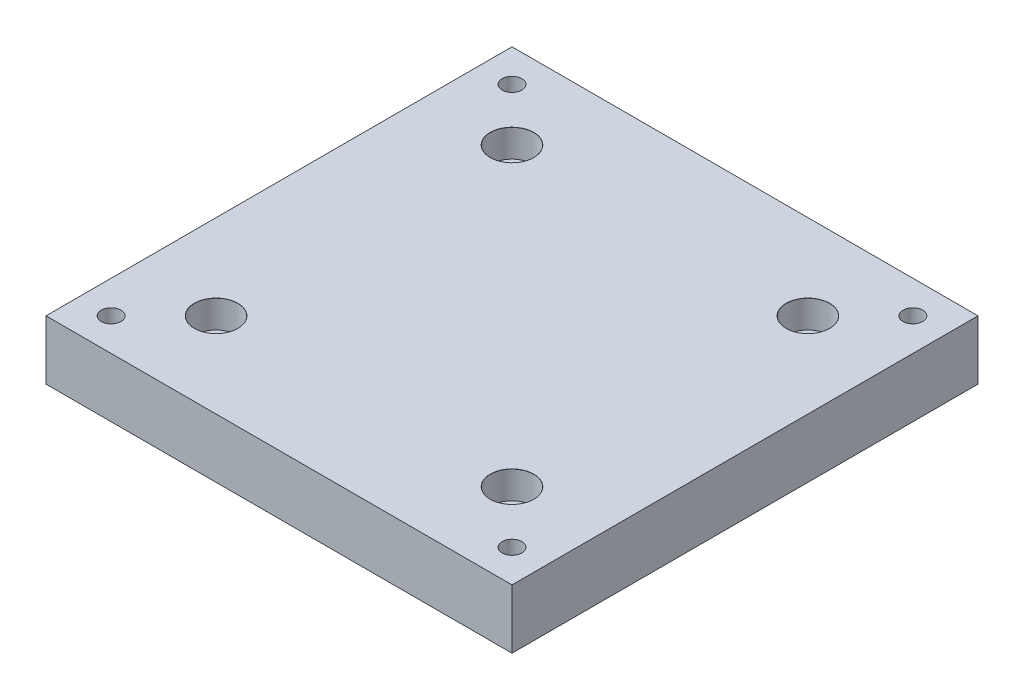
from build123d import *

# Parameters (mm, degrees)
SKETCH1_W                     = 118.11
SKETCH1_H                     = 118.11
BOSS_EXTRUDE1_DEPTH           = 15
CBORE_FOR_M6_SHCS1_AT_2_COUNT = 2
CBORE_FOR_M6_SHCS1_AT_2_PITCH = 75
CBORE_FOR_M6_SHCS1_AT_3_COUNT = 2
CBORE_FOR_M6_SHCS1_AT_3_PITCH = 106.066017178
CBORE_FOR_M6_SHCS1_AT_4_COUNT = 2
CBORE_FOR_M6_SHCS1_AT_4_PITCH = 75
M6X1_0_TAPPED_HOLE1_D         = 5
M6X1_0_TAPPED_HOLE1_DEPTH     = 10
M6X1_0_TAPPED_HOLE1_TIP       = 1.502151548


with BuildPart() as part:
    # Sketch1 → Boss-Extrude1 (new body)
    with BuildSketch(Plane(origin=(0, 0, 0), x_dir=(1, 0, 0), z_dir=(0, 1, 0))):
        Rectangle(SKETCH1_W, SKETCH1_H)
    extrude(amount=-BOSS_EXTRUDE1_DEPTH)

    # Sketch5 → CBORE for M6 SHCS1 (revolve, cut)
    with BuildSketch(Plane(origin=(-37.5, 0, 37.5), x_dir=(0, 0, 1), z_dir=(1, 0, 0))):
        Polygon((0, 0), (0, 16.982840043), (3.3, 15), (3.3, 7), (5.5, 7), (5.5, 0.025), (5.525, 0), align=None)
    cbore_for_m6_shcs1 = revolve(axis=Axis((-37.5, 6.35, 37.5), (0, -1, 0)), mode=Mode.SUBTRACT)

    # CBORE for M6 SHCS1 at 2: CBORE for M6 SHCS1 ×2
    with Locations(*[(i * CBORE_FOR_M6_SHCS1_AT_2_PITCH, 0, 0) for i in range(1, CBORE_FOR_M6_SHCS1_AT_2_COUNT)]):
        add(cbore_for_m6_shcs1, mode=Mode.SUBTRACT)

    # CBORE for M6 SHCS1 at 3: CBORE for M6 SHCS1 ×2
    with Locations(*[Vector(0.707106781, 0, -0.707106781) * (i * CBORE_FOR_M6_SHCS1_AT_3_PITCH) for i in range(1, CBORE_FOR_M6_SHCS1_AT_3_COUNT)]):
        add(cbore_for_m6_shcs1, mode=Mode.SUBTRACT)

    # CBORE for M6 SHCS1 at 4: CBORE for M6 SHCS1 ×2
    with Locations(*[(0, 0, -i * CBORE_FOR_M6_SHCS1_AT_4_PITCH) for i in range(1, CBORE_FOR_M6_SHCS1_AT_4_COUNT)]):
        add(cbore_for_m6_shcs1, mode=Mode.SUBTRACT)

    # M6x1.0 Tapped Hole1
    with Locations(Plane(origin=(0, 0, 0), x_dir=(1, 0, 0), z_dir=(0, 1, 0))):
        with Locations((-50.8, -50.8), (-50.8, 50.8), (50.8, 50.8), (50.8, -50.8)):
            Hole(M6X1_0_TAPPED_HOLE1_D / 2, depth=M6X1_0_TAPPED_HOLE1_DEPTH)
            with Locations((0, 0, -(M6X1_0_TAPPED_HOLE1_DEPTH + M6X1_0_TAPPED_HOLE1_TIP / 2))):  # 118° drill point
                Cone(0, M6X1_0_TAPPED_HOLE1_D / 2, M6X1_0_TAPPED_HOLE1_TIP, mode=Mode.SUBTRACT)


solid = part.part
